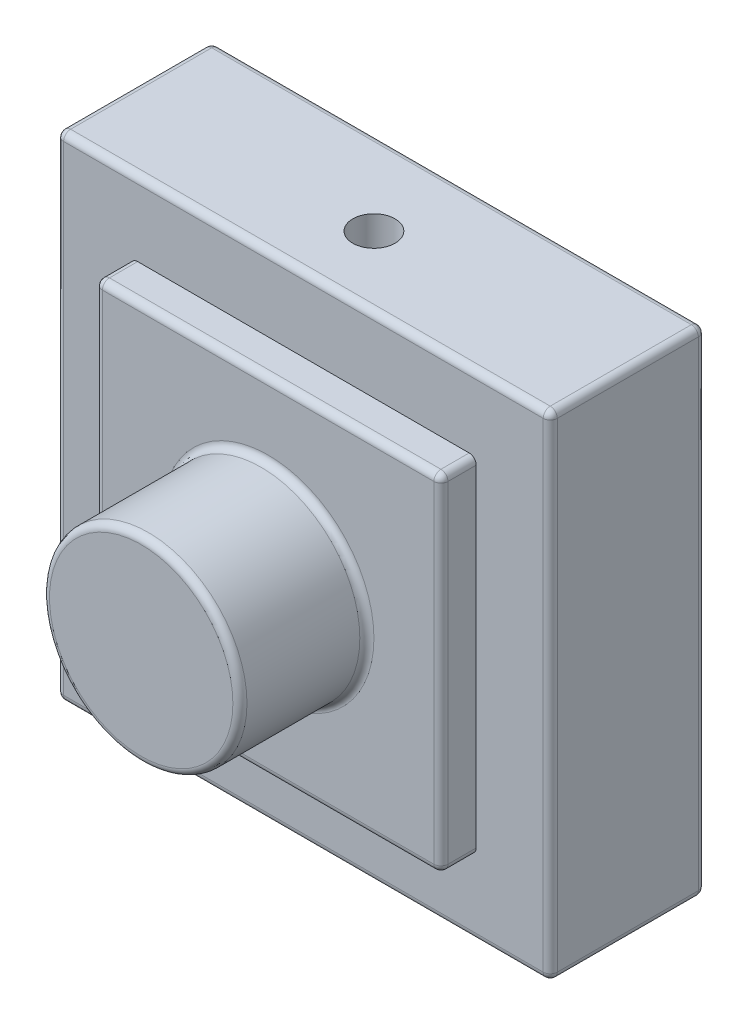
from build123d import *

# Parameters (mm, degrees)
SKETCH1_W           = 35
SKETCH1_H           = 35
BOSS_EXTRUDE1_DEPTH = 11
SKETCH2_R           = 1.5
CUT_EXTRUDE1_DEPTH  = 5
SKETCH3_W           = 24.5
SKETCH3_H           = 24.5
BOSS_EXTRUDE2_DEPTH = 2.5
SKETCH4_R           = 7
BOSS_EXTRUDE3_DEPTH = 9
FILLET1_R           = 0.5
FILLET2_R           = 0.5


with BuildPart() as part:
    # Sketch1 → Boss-Extrude1 (new body)
    with BuildSketch(Plane.XY):
        Rectangle(SKETCH1_W, SKETCH1_H)
    extrude(amount=BOSS_EXTRUDE1_DEPTH)

    # Sketch2 → Cut-Extrude1 (cut)
    with BuildSketch(Plane(origin=(0, 17.5, 0), x_dir=(1, 0, 0), z_dir=(0, 1, 0))):
        with Locations((0, -6)):
            Circle(SKETCH2_R)
    cut_extrude1 = extrude(amount=-CUT_EXTRUDE1_DEPTH, mode=Mode.SUBTRACT)

    # Mirror1: Cut-Extrude1 across plane
    add(cut_extrude1.mirror(Plane.ZX), mode=Mode.SUBTRACT)

    # Sketch3 → Boss-Extrude2 (add)
    with BuildSketch(Plane.XY.offset(11)):
        Rectangle(SKETCH3_W, SKETCH3_H)
    extrude(amount=BOSS_EXTRUDE2_DEPTH)

    # Sketch4 → Boss-Extrude3 (add)
    with BuildSketch(Plane.XY.offset(13.5)):
        Circle(SKETCH4_R)
    extrude(amount=BOSS_EXTRUDE3_DEPTH)

    # Fillet1
    fillet1_edges = [part.edges().sort_by_distance(p)[0] for p in [
        (-17.5, 0, 11),
        (0, -17.5, 11),
        (12.25, -12.25, 12.25),
        (12.25, 12.25, 12.25),
        (-12.25, 12.25, 12.25),
        (-12.25, -12.25, 12.25),
        (12.25, 0, 13.5),
        (0, 12.25, 13.5),
        (-12.25, 0, 13.5),
        (0, -12.25, 13.5),
        (-7, 0, 13.5),
        (17.5, 0, 11),
        (0, -17.5, 0),
        (-17.5, 0, 0),
        (0, 17.5, 0),
        (17.5, 0, 0),
        (0, 17.5, 11),
        (17.5, -17.5, 5.5),
        (-17.5, -17.5, 5.5),
        (-17.5, 17.5, 5.5),
        (17.5, 17.5, 5.5),
    ]]
    fillet(fillet1_edges, radius=FILLET1_R)

    # Fillet2
    fillet2_edges = [part.edges().sort_by_distance(p)[0] for p in [
        (-7, 0, 22.5),
    ]]
    fillet(fillet2_edges, radius=FILLET2_R)


solid = part.part
